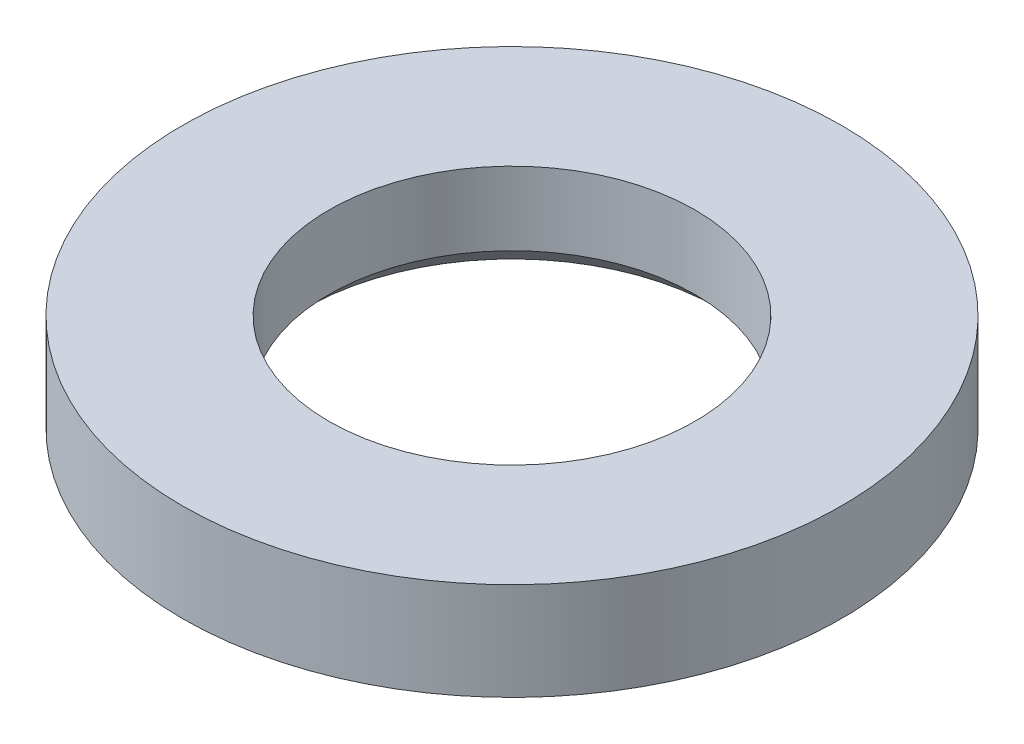
from build123d import *

# Parameters (mm, degrees)
SKETCH1_W     = 1.2
SKETCH1_H     = 0.8
CHAMFER1_SIZE = 0.2


with BuildPart() as part:
    # Sketch1 → Revolve1 (revolve)
    with BuildSketch(Plane.XY):
        with Locations((2.1, 0.4)):
            Rectangle(SKETCH1_W, SKETCH1_H)
    revolve(axis=Axis((0, 0, 0), (0, 1, 0)))

    # Chamfer1
    chamfer1_edges = [part.edges().sort_by_distance(p)[0] for p in [
        (-1.5, 0, 0),
    ]]
    chamfer(chamfer1_edges, length=CHAMFER1_SIZE)


solid = part.part
